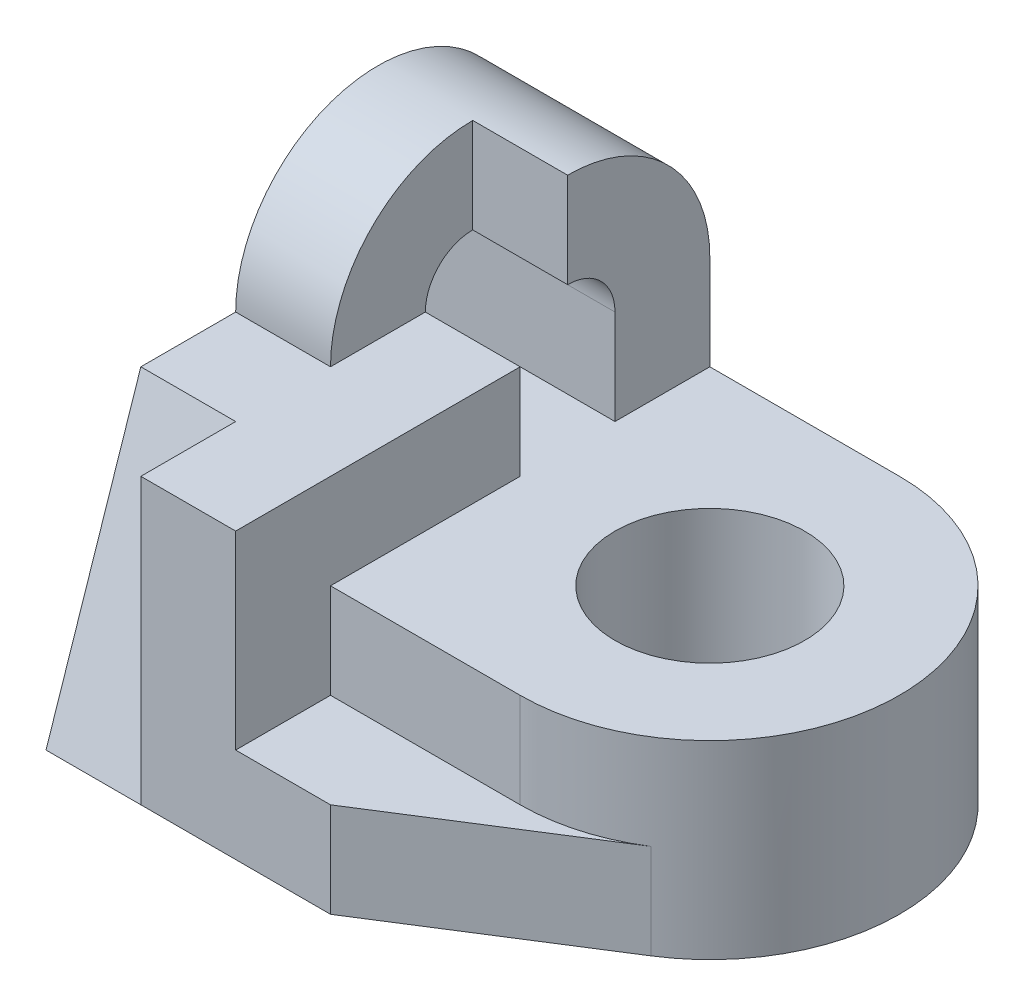
from build123d import *

# Parameters (mm, degrees)
SKETCH1_W           = 4
SKETCH1_H           = 2
BOSS_EXTRUDE1_DEPTH = 4
BOSS_EXTRUDE2_DEPTH = 2
SKETCH3_R           = 1
CUT_EXTRUDE1_DEPTH  = 3
BOSS_EXTRUDE4_DEPTH = 2
CUT_EXTRUDE2_DEPTH  = 1
SKETCH8_W           = 1
SKETCH8_H           = 2
BOSS_EXTRUDE5_DEPTH = 2
CUT_EXTRUDE3_DEPTH  = 1
BOSS_EXTRUDE6_DEPTH = 1
BOSS_EXTRUDE7_DEPTH = 1
BOSS_EXTRUDE8_DEPTH = 1


with BuildPart() as part:
    # Sketch1 → Boss-Extrude1 (new body)
    with BuildSketch(Plane.XY):
        Rectangle(SKETCH1_W, SKETCH1_H)
    extrude(amount=BOSS_EXTRUDE1_DEPTH)

    # Sketch2 → Boss-Extrude2 (add)
    with BuildSketch(Plane(origin=(0, 1, 0), x_dir=(1, 0, 0), z_dir=(0, 1, 0))):
        with BuildLine():
            Line((2, 0), (2, -4))
            ThreePointArc((2, -4), (4, -2), (2, 0))
        make_face()
    extrude(amount=-BOSS_EXTRUDE2_DEPTH)

    # Sketch3 → Cut-Extrude1 (cut, through all)
    with BuildSketch(Plane(origin=(0, 1, 0), x_dir=(1, 0, 0), z_dir=(0, 1, 0))):
        with Locations((2, -2)):
            Circle(SKETCH3_R)
    extrude(amount=-CUT_EXTRUDE1_DEPTH, mode=Mode.SUBTRACT)

    # Sketch4 → Boss-Extrude4 (add)
    with BuildSketch(Plane.ZY.offset(2)):
        with BuildLine():
            Line((0, 1), (0, 2))
            ThreePointArc((0, 2), (1.5, 3.5), (3, 2))
            Line((3, 2), (3, 1))
            Line((3, 1), (2, 1))
            Line((2, 1), (2, 2))
            ThreePointArc((2, 2), (1.5, 2.5), (1, 2))
            Line((1, 2), (1, 1))
            Line((1, 1), (0, 1))
        make_face()
    extrude(amount=-BOSS_EXTRUDE4_DEPTH)

    # Sketch7 → Cut-Extrude2 (cut)
    with BuildSketch(Plane(origin=(0, 0, 0), x_dir=(0, 0, -1), z_dir=(1, 0, 0))):
        with BuildLine():
            Line((-1.5, 2.5), (-1.5, 3.5))
            ThreePointArc((-1.5, 3.5), (-2.560660172, 3.060660172), (-3, 2))
            Line((-3, 2), (-2, 2))
            ThreePointArc((-2, 2), (-1.853553391, 2.353553391), (-1.5, 2.5))
        make_face()
    extrude(amount=-CUT_EXTRUDE2_DEPTH, mode=Mode.SUBTRACT)

    # Sketch8 → Boss-Extrude5 (add)
    with BuildSketch(Plane.ZY.offset(2)):
        with Locations((4.5, 0)):
            Rectangle(SKETCH8_W, SKETCH8_H)
    extrude(amount=-BOSS_EXTRUDE5_DEPTH)

    # Sketch9 → Cut-Extrude3 (cut)
    with BuildSketch(Plane.ZY.offset(2)):
        Polygon((5, 1), (4, 1), (5, -1), align=None)
    extrude(amount=-CUT_EXTRUDE3_DEPTH, mode=Mode.SUBTRACT)

    # Sketch10 → Boss-Extrude6 (add)
    with BuildSketch(Plane(origin=(0, -1, 0), x_dir=(-1, 0, 0), z_dir=(0, -1, 0))):
        with BuildLine():
            Line((0, -5), (-1, -5))
            Line((-1, -5), (-3.069693846, -3.689897949))
            ThreePointArc((-3.069693846, -3.689897949), (-2.556868074, -3.920910708), (-2, -4))
            Line((-2, -4), (0, -4))
            Line((0, -4), (0, -5))
        make_face()
    extrude(amount=-BOSS_EXTRUDE6_DEPTH)

    # Sketch11 → Boss-Extrude7 (add)
    with BuildSketch(Plane(origin=(0, 1, 0), x_dir=(1, 0, 0), z_dir=(0, 1, 0))):
        Polygon((0, -3), (0, -5), (-1, -5), (-1, -4), (-2, -4), (-2, -3), align=None)
    extrude(amount=BOSS_EXTRUDE7_DEPTH)

    # Sketch12 → Boss-Extrude8 (add)
    with BuildSketch(Plane.ZY.offset(1)):
        Polygon((4, 2), (5, -1), (4, 1), align=None)
    extrude(amount=BOSS_EXTRUDE8_DEPTH)


solid = part.part
